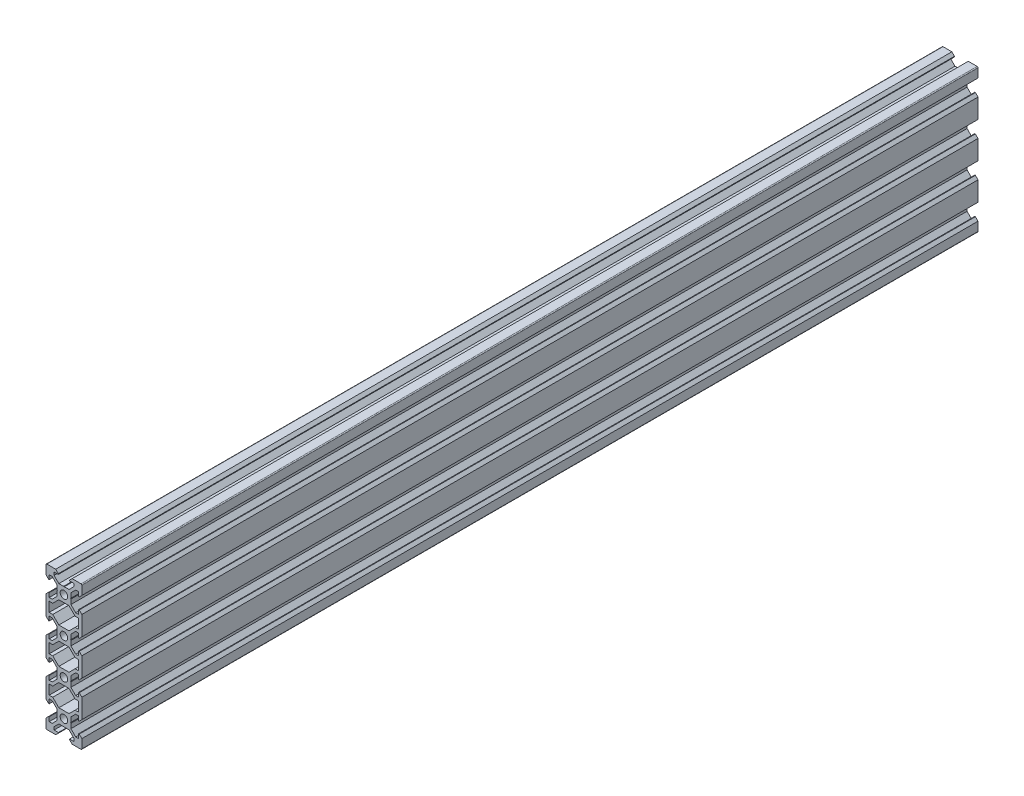
from build123d import *

# Parameters (mm, degrees)
SKETCH1_R           = 2.1
BOSS_EXTRUDE1_DEPTH = 500


with BuildPart() as part:
    # Sketch1 → Boss-Extrude1 (new body)
    with BuildSketch(Plane.XY):
        with BuildLine():
            Line((3.69, 0), (3.9, -0.21))
            Line((3.9, -0.21), (3.9, -2.839339828))
            Line((3.9, -2.839339828), (6.560660172, -5.5))
            Line((6.560660172, -5.5), (8.2, -5.5))
            Line((8.2, -5.5), (8.2, -3.125))
            Line((8.2, -3.125), (8.545, -3.125))
            Line((8.545, -3.125), (10, -4.58))
            Line((10, -4.58), (10, -15.42))
            Line((10, -15.42), (8.545, -16.875))
            Line((8.545, -16.875), (8.2, -16.875))
            Line((8.2, -16.875), (8.2, -14.5))
            Line((8.2, -14.5), (6.560660172, -14.5))
            Line((6.560660172, -14.5), (3.9, -17.160660172))
            Line((3.9, -17.160660172), (3.9, -19.79))
            Line((3.9, -19.79), (3.69, -20))
            Line((3.69, -20), (3.9, -20.21))
            Line((3.9, -20.21), (3.9, -22.839339828))
            Line((3.9, -22.839339828), (6.560660172, -25.5))
            Line((6.560660172, -25.5), (8.2, -25.5))
            Line((8.2, -25.5), (8.2, -23.125))
            Line((8.2, -23.125), (8.545, -23.125))
            Line((8.545, -23.125), (10, -24.58))
            Line((10, -24.58), (10, -35.42))
            Line((10, -35.42), (8.545, -36.875))
            Line((8.545, -36.875), (8.2, -36.875))
            Line((8.2, -36.875), (8.2, -34.5))
            Line((8.2, -34.5), (6.560660172, -34.5))
            Line((6.560660172, -34.5), (3.9, -37.160660172))
            Line((3.9, -37.160660172), (3.9, -39.79))
            Line((3.9, -39.79), (3.69, -40))
            Line((3.69, -40), (3.9, -40.21))
            Line((3.9, -40.21), (3.9, -42.839339828))
            Line((3.9, -42.839339828), (6.560660172, -45.5))
            Line((6.560660172, -45.5), (8.2, -45.5))
            Line((8.2, -45.5), (8.2, -43.125))
            Line((8.2, -43.125), (8.545, -43.125))
            Line((8.545, -43.125), (10, -44.58))
            Line((10, -44.58), (10, -55.42))
            Line((10, -55.42), (8.545, -56.875))
            Line((8.545, -56.875), (8.2, -56.875))
            Line((8.2, -56.875), (8.2, -54.5))
            Line((8.2, -54.5), (6.560660172, -54.5))
            Line((6.560660172, -54.5), (3.9, -57.160660172))
            Line((3.9, -57.160660172), (3.9, -59.79))
            Line((3.9, -59.79), (3.69, -60))
            Line((3.69, -60), (3.9, -60.21))
            Line((3.9, -60.21), (3.9, -62.839339828))
            Line((3.9, -62.839339828), (6.560660172, -65.5))
            Line((6.560660172, -65.5), (8.2, -65.5))
            Line((8.2, -65.5), (8.2, -63.125))
            Line((8.2, -63.125), (8.545, -63.125))
            Line((8.545, -63.125), (10, -64.58))
            Line((10, -64.58), (10, -69.5))
            ThreePointArc((10, -69.5), (9.853553391, -69.853553391), (9.5, -70))
            Line((9.5, -70), (4.58, -70))
            Line((4.58, -70), (3.125, -68.545))
            Line((3.125, -68.545), (3.125, -68.2))
            Line((3.125, -68.2), (5.5, -68.2))
            Line((5.5, -68.2), (5.5, -66.560660172))
            Line((5.5, -66.560660172), (2.839339828, -63.9))
            Line((2.839339828, -63.9), (0.21, -63.9))
            Line((0.21, -63.9), (0, -63.69))
            Line((0, -63.69), (-0.21, -63.9))
            Line((-0.21, -63.9), (-2.839339828, -63.9))
            Line((-2.839339828, -63.9), (-5.5, -66.560660172))
            Line((-5.5, -66.560660172), (-5.5, -68.2))
            Line((-5.5, -68.2), (-3.125, -68.2))
            Line((-3.125, -68.2), (-3.125, -68.545))
            Line((-3.125, -68.545), (-4.58, -70))
            Line((-4.58, -70), (-9.5, -70))
            ThreePointArc((-9.5, -70), (-9.853553391, -69.853553391), (-10, -69.5))
            Line((-10, -69.5), (-10, -64.58))
            Line((-10, -64.58), (-8.545, -63.125))
            Line((-8.545, -63.125), (-8.2, -63.125))
            Line((-8.2, -63.125), (-8.2, -65.5))
            Line((-8.2, -65.5), (-6.560660172, -65.5))
            Line((-6.560660172, -65.5), (-3.9, -62.839339828))
            Line((-3.9, -62.839339828), (-3.9, -60.21))
            Line((-3.9, -60.21), (-3.69, -60))
            Line((-3.69, -60), (-3.9, -59.79))
            Line((-3.9, -59.79), (-3.9, -57.160660172))
            Line((-3.9, -57.160660172), (-6.560660172, -54.5))
            Line((-6.560660172, -54.5), (-8.2, -54.5))
            Line((-8.2, -54.5), (-8.2, -56.875))
            Line((-8.2, -56.875), (-8.545, -56.875))
            Line((-8.545, -56.875), (-10, -55.42))
            Line((-10, -55.42), (-10, -44.58))
            Line((-10, -44.58), (-8.545, -43.125))
            Line((-8.545, -43.125), (-8.2, -43.125))
            Line((-8.2, -43.125), (-8.2, -45.5))
            Line((-8.2, -45.5), (-6.560660172, -45.5))
            Line((-6.560660172, -45.5), (-3.9, -42.839339828))
            Line((-3.9, -42.839339828), (-3.9, -40.21))
            Line((-3.9, -40.21), (-3.69, -40))
            Line((-3.69, -40), (-3.9, -39.79))
            Line((-3.9, -39.79), (-3.9, -37.160660172))
            Line((-3.9, -37.160660172), (-6.560660172, -34.5))
            Line((-6.560660172, -34.5), (-8.2, -34.5))
            Line((-8.2, -34.5), (-8.2, -36.875))
            Line((-8.2, -36.875), (-8.545, -36.875))
            Line((-8.545, -36.875), (-10, -35.42))
            Line((-10, -35.42), (-10, -24.58))
            Line((-10, -24.58), (-8.545, -23.125))
            Line((-8.545, -23.125), (-8.2, -23.125))
            Line((-8.2, -23.125), (-8.2, -25.5))
            Line((-8.2, -25.5), (-6.560660172, -25.5))
            Line((-6.560660172, -25.5), (-3.9, -22.839339828))
            Line((-3.9, -22.839339828), (-3.9, -20.21))
            Line((-3.9, -20.21), (-3.69, -20))
            Line((-3.69, -20), (-3.9, -19.79))
            Line((-3.9, -19.79), (-3.9, -17.160660172))
            Line((-3.9, -17.160660172), (-6.560660172, -14.5))
            Line((-6.560660172, -14.5), (-8.2, -14.5))
            Line((-8.2, -14.5), (-8.2, -16.875))
            Line((-8.2, -16.875), (-8.545, -16.875))
            Line((-8.545, -16.875), (-10, -15.42))
            Line((-10, -15.42), (-10, -4.58))
            Line((-10, -4.58), (-8.545, -3.125))
            Line((-8.545, -3.125), (-8.2, -3.125))
            Line((-8.2, -3.125), (-8.2, -5.5))
            Line((-8.2, -5.5), (-6.560660172, -5.5))
            Line((-6.560660172, -5.5), (-3.9, -2.839339828))
            Line((-3.9, -2.839339828), (-3.9, -0.21))
            Line((-3.9, -0.21), (-3.69, 0))
            Line((-3.69, 0), (-3.9, 0.21))
            Line((-3.9, 0.21), (-3.9, 2.839339828))
            Line((-3.9, 2.839339828), (-6.560660172, 5.5))
            Line((-6.560660172, 5.5), (-8.2, 5.5))
            Line((-8.2, 5.5), (-8.2, 3.125))
            Line((-8.2, 3.125), (-8.545, 3.125))
            Line((-8.545, 3.125), (-10, 4.58))
            Line((-10, 4.58), (-10, 9.5))
            ThreePointArc((-10, 9.5), (-9.853553391, 9.853553391), (-9.5, 10))
            Line((-9.5, 10), (-4.58, 10))
            Line((-4.58, 10), (-3.125, 8.545))
            Line((-3.125, 8.545), (-3.125, 8.2))
            Line((-3.125, 8.2), (-5.5, 8.2))
            Line((-5.5, 8.2), (-5.5, 6.560660172))
            Line((-5.5, 6.560660172), (-2.839339828, 3.9))
            Line((-2.839339828, 3.9), (-0.21, 3.9))
            Line((-0.21, 3.9), (0, 3.69))
            Line((0, 3.69), (0.21, 3.9))
            Line((0.21, 3.9), (2.839339828, 3.9))
            Line((2.839339828, 3.9), (5.5, 6.560660172))
            Line((5.5, 6.560660172), (5.5, 8.2))
            Line((5.5, 8.2), (3.125, 8.2))
            Line((3.125, 8.2), (3.125, 8.545))
            Line((3.125, 8.545), (4.58, 10))
            Line((4.58, 10), (9.5, 10))
            ThreePointArc((9.5, 10), (9.853553391, 9.853553391), (10, 9.5))
            Line((10, 9.5), (10, 4.58))
            Line((10, 4.58), (8.545, 3.125))
            Line((8.545, 3.125), (8.2, 3.125))
            Line((8.2, 3.125), (8.2, 5.5))
            Line((8.2, 5.5), (6.560660172, 5.5))
            Line((6.560660172, 5.5), (3.9, 2.839339828))
            Line((3.9, 2.839339828), (3.9, 0.21))
            Line((3.9, 0.21), (3.69, 0))
        make_face()
        with Locations((0, -60)):
            Circle(SKETCH1_R, mode=Mode.SUBTRACT)
        Circle(SKETCH1_R, mode=Mode.SUBTRACT)
        with Locations((0, -20)):
            Circle(SKETCH1_R, mode=Mode.SUBTRACT)
        with Locations((0, -40)):
            Circle(SKETCH1_R, mode=Mode.SUBTRACT)
        Polygon((-8.2, -52.7), (-6.239339828, -52.7), (-2.839339828, -56.1), (2.839339828, -56.1), (6.239339828, -52.7), (8.2, -52.7), (8.2, -47.3), (6.239339828, -47.3), (2.839339828, -43.9), (-2.839339828, -43.9), (-6.239339828, -47.3), (-8.2, -47.3), align=None, mode=Mode.SUBTRACT)
        Polygon((-8.2, -32.7), (-6.239339828, -32.7), (-2.839339828, -36.1), (2.839339828, -36.1), (6.239339828, -32.7), (8.2, -32.7), (8.2, -27.3), (6.239339828, -27.3), (2.839339828, -23.9), (-2.839339828, -23.9), (-6.239339828, -27.3), (-8.2, -27.3), align=None, mode=Mode.SUBTRACT)
        Polygon((-8.2, -12.7), (-6.239339828, -12.7), (-2.839339828, -16.1), (2.839339828, -16.1), (6.239339828, -12.7), (8.2, -12.7), (8.2, -7.3), (6.239339828, -7.3), (2.839339828, -3.9), (-2.839339828, -3.9), (-6.239339828, -7.3), (-8.2, -7.3), align=None, mode=Mode.SUBTRACT)
    extrude(amount=BOSS_EXTRUDE1_DEPTH)


solid = part.part
